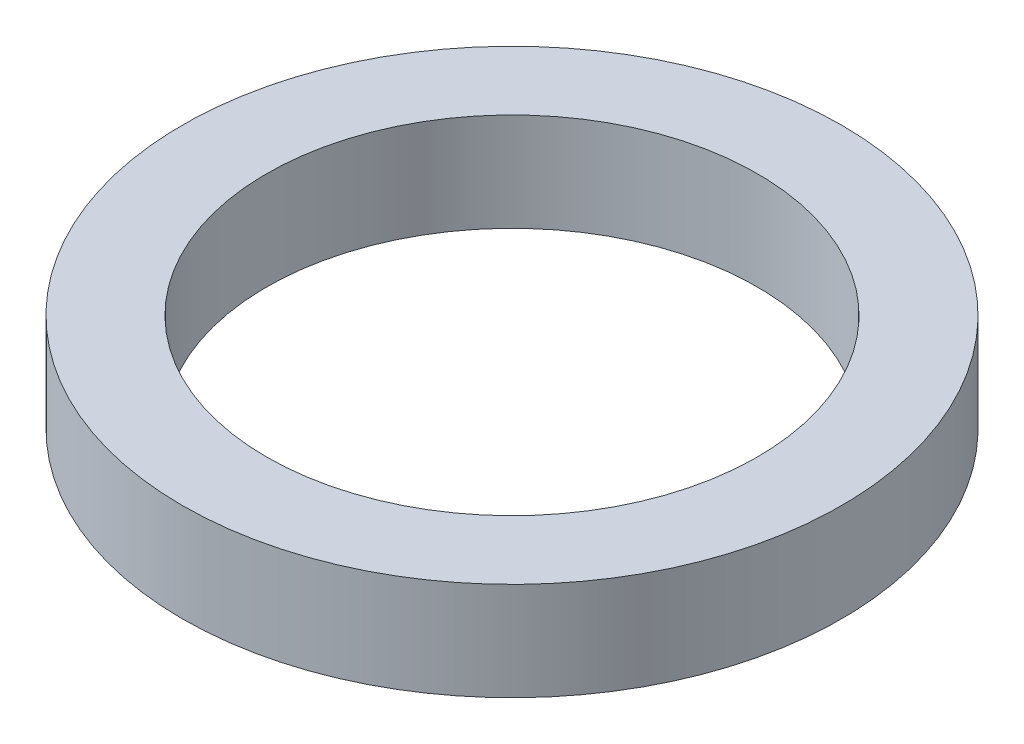
from build123d import *

# Parameters (mm, degrees)
SKETCH1_R           = 23.5
SKETCH1_R_2         = 17.5
BOSS_EXTRUDE1_DEPTH = 7


with BuildPart() as part:
    # Sketch1 → Boss-Extrude1 (new body)
    with BuildSketch(Plane(origin=(0, 0, 0), x_dir=(1, 0, 0), z_dir=(0, 1, 0))):
        Circle(SKETCH1_R)
        Circle(SKETCH1_R_2, mode=Mode.SUBTRACT)
    extrude(amount=BOSS_EXTRUDE1_DEPTH)


solid = part.part
